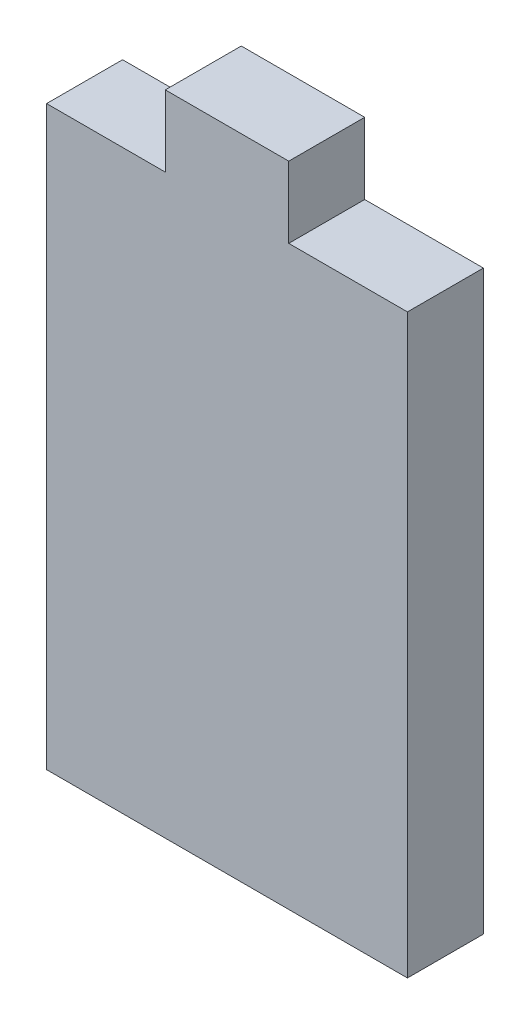
from build123d import *

# Parameters (mm, degrees)
SKETCH2_W           = 38.608
SKETCH2_H           = 8.128
BOSS_EXTRUDE1_DEPTH = 61.722
SKETCH3_W           = 13.208
SKETCH3_H           = 8.128
BOSS_EXTRUDE2_DEPTH = 7.62


with BuildPart() as part:
    # Sketch2 → Boss-Extrude1 (new body)
    with BuildSketch(Plane(origin=(0, 0, 0), x_dir=(1, 0, 0), z_dir=(0, 1, 0))):
        Rectangle(SKETCH2_W, SKETCH2_H)
    extrude(amount=BOSS_EXTRUDE1_DEPTH)

    # Sketch3 → Boss-Extrude2 (add)
    with BuildSketch(Plane(origin=(0, 61.722, 0), x_dir=(1, 0, 0), z_dir=(0, 1, 0))):
        Rectangle(SKETCH3_W, SKETCH3_H)
    extrude(amount=BOSS_EXTRUDE2_DEPTH)


solid = part.part
